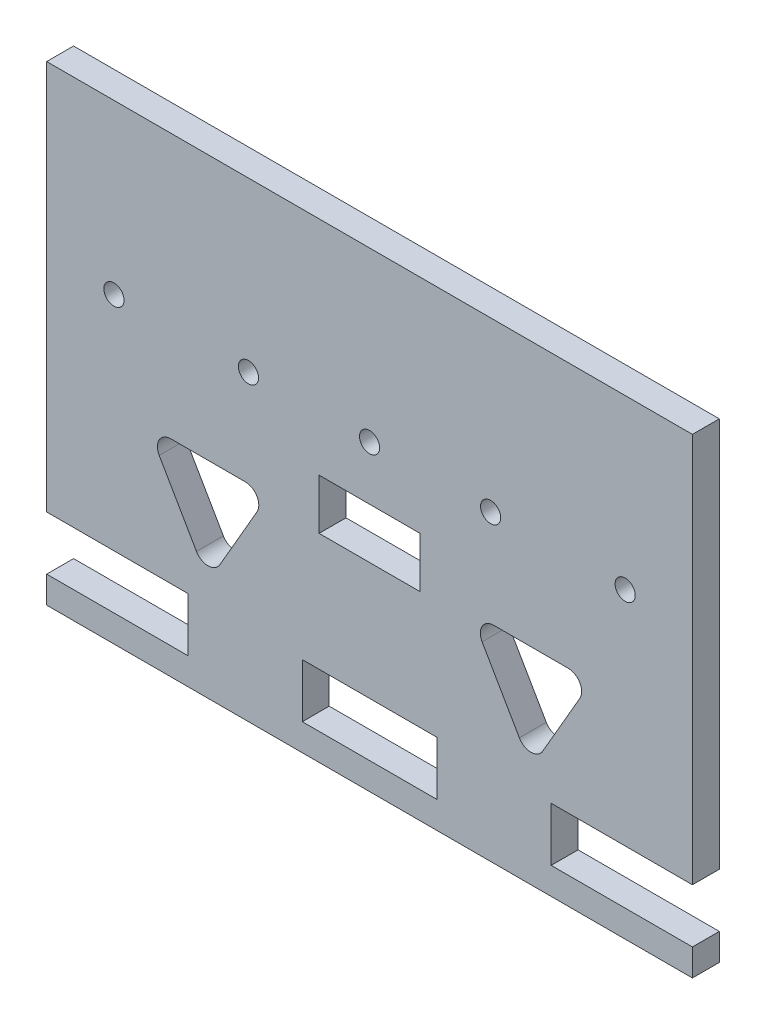
from build123d import *

# Parameters (mm, degrees)
ESBO_O1_R                = 1.5
ESBO_O1_W                = 20
ESBO_O1_H                = 8
ESBO_O1_W_2              = 15
ESBO_O1_H_2              = 7.5
RESSALTO_EXTRUS_O1_DEPTH = 4
CORTE_EXTRUS_O1_DEPTH    = 10
FILETE1_R                = 2
ESBO_O3_R                = 1.25
CORTE_EXTRUS_O2_DEPTH    = 12


with BuildPart() as part:
    # Esboço1 → Ressalto-extrusão1 (new body)
    with BuildSketch(Plane.XY):
        Polygon((0, 0), (96.01, 0), (96.01, -58), (75.01, -58), (75.01, -66), (96.01, -66), (96.01, -70), (0, -70), (0, -66), (21, -66), (21, -58), (0, -58), align=None)
        with Locations((48.005, -25)):
            Circle(ESBO_O1_R, mode=Mode.SUBTRACT)
        with Locations((86.01, -25)):
            Circle(ESBO_O1_R, mode=Mode.SUBTRACT)
        with Locations((10, -25)):
            Circle(ESBO_O1_R, mode=Mode.SUBTRACT)
        with Locations((66.01, -25)):
            Circle(ESBO_O1_R, mode=Mode.SUBTRACT)
        with Locations((30, -25)):
            Circle(ESBO_O1_R, mode=Mode.SUBTRACT)
        with Locations((48.005, -62)):
            Rectangle(ESBO_O1_W, ESBO_O1_H, mode=Mode.SUBTRACT)
        with Locations((48.005, -36.75)):
            Rectangle(ESBO_O1_W_2, ESBO_O1_H_2, mode=Mode.SUBTRACT)
    extrude(amount=RESSALTO_EXTRUS_O1_DEPTH)

    # Esboço2 → Corte-extrusão1 (cut)
    with BuildSketch(Plane.XY.offset(4)):
        Polygon((63.01, -39.351037912), (81.01, -39.351037912), (72.01, -54.93949518), align=None)
        Polygon((15, -39.351037912), (33, -39.351037912), (24, -54.93949518), align=None)
    extrude(amount=-CORTE_EXTRUS_O1_DEPTH, mode=Mode.SUBTRACT)

    # Filete1
    filete1_edges = [part.edges().sort_by_distance(p)[0] for p in [
        (72.01, -54.93949518, 2),
        (63.01, -39.351037912, 2),
        (81.01, -39.351037912, 2),
        (24, -54.93949518, 2),
        (15, -39.351037912, 2),
        (33, -39.351037912, 2),
    ]]
    fillet(filete1_edges, radius=FILETE1_R)

    # Esboço3 → Corte-extrusão2 (cut)
    with BuildSketch(Plane.XZ.offset(70)):
        with Locations((25, 2)):
            Circle(ESBO_O3_R)
        with Locations((34, 2)):
            Circle(ESBO_O3_R)
        with Locations((62.01, 2)):
            Circle(ESBO_O3_R)
        with Locations((71.01, 2)):
            Circle(ESBO_O3_R)
    extrude(amount=-CORTE_EXTRUS_O2_DEPTH, mode=Mode.SUBTRACT)


solid = part.part
